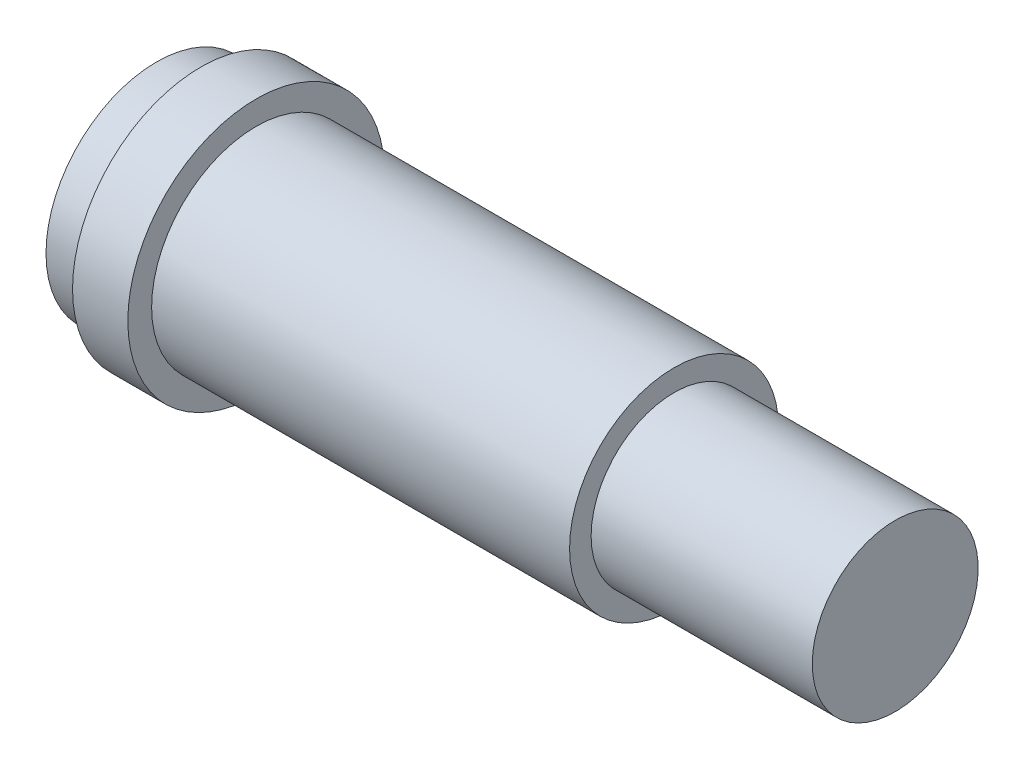
from build123d import *

# Parameters (mm, degrees)
SKETCH2_R          = 6.35
CUT_EXTRUDE1_DEPTH = 4.4925


with BuildPart() as part:
    # Sketch1 → Revolve1 (revolve)
    with BuildSketch(Plane.XY):
        Polygon((-6.35, 0), (18.35, 0), (18.35, 2.38125), (12, 2.38125), (12, 3), (0, 3), (0, 3.683), (-1.5875, 3.683), (-1.5875, 3.175), (-6.35, 3.175), align=None)
    revolve(axis=Axis((-160.130718954, 0, 0), (1, 0, 0)))

    # Sketch2 → Cut-Extrude1 (cut, through all)
    with BuildSketch(Plane(origin=(-2.8575, -8.19662542, -7.078645384), x_dir=(0, -0.923004378, -0.384789447), z_dir=(1, 0, 0))):
        with Locations((-10.289309191, -3.379645711)):
            Circle(SKETCH2_R)
    extrude(amount=-CUT_EXTRUDE1_DEPTH, mode=Mode.SUBTRACT)


solid = part.part
